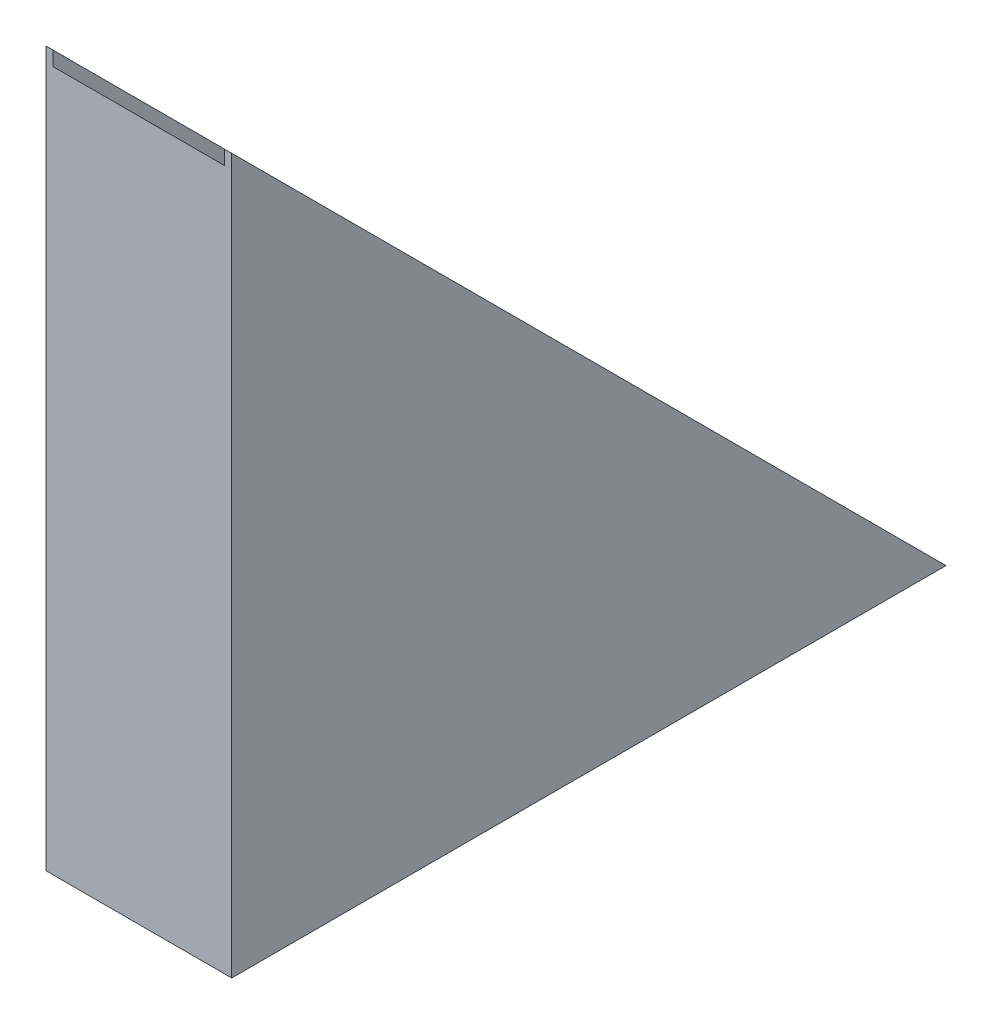
from build123d import *

# Parameters (mm, degrees)
BOSS_EXTRUDE1_DEPTH = 650
SKETCH2_W           = 600
SKETCH2_H           = 50


with BuildPart() as part:
    # Sketch1 → Boss-Extrude1 (new body)
    with BuildSketch(Plane(origin=(0, 0, 0), x_dir=(0, 0, -1), z_dir=(1, 0, 0))):
        Polygon((0, 0), (2500, 0), (0, 2500), align=None)
    extrude(amount=BOSS_EXTRUDE1_DEPTH)

    # Cut-Sweep1: sweep along a curve in space
    with BuildLine() as cut_sweep1_path:
        Line((0, 0, -2500), (0, 2500, 0))
    # Sketch2 → Cut-Sweep1 (sweep, cut)
    with BuildSketch(Plane.XY):
        with Locations((325, 2475)):
            Rectangle(SKETCH2_W, SKETCH2_H)
    sweep(path=cut_sweep1_path.line, mode=Mode.SUBTRACT)


solid = part.part
